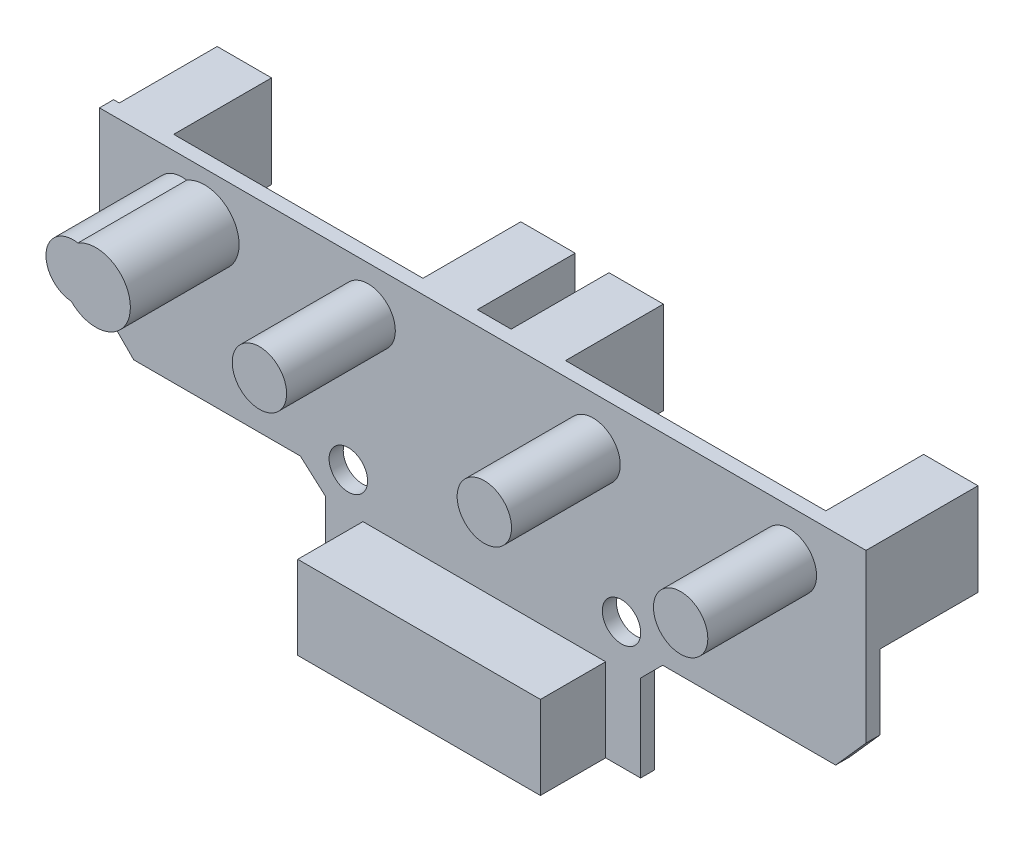
from build123d import *

# Parameters (mm, degrees)
EXTRUDE_1_DEPTH     = 1.3
SKETCH_2_R          = 6.1271e-05
SKETCH_2_R_2        = 1.854699803
CUT_EXTRUDE_1_DEPTH = 1.3
SKETCH_3_W          = 5
SKETCH_3_H          = 8.5
EXTRUDE_2_DEPTH     = 9
SKETCH_4_W          = 22.322793398
SKETCH_4_H          = 7.656611546
EXTRUDE_3_DEPTH     = 6
SKETCH_7_R          = 2.060894962
SKETCH_7_R_2        = 0.009430026
EXTRUDE_6_DEPTH     = 1.3
SKETCH_9_R          = 1.766576119
SKETCH_9_R_2        = 1.77
CUT_EXTRUDE_4_DEPTH = 13.5
SKETCH_11_R         = 2.5
EXTRUDE_7_DEPTH     = 10
SKETCH_5_R          = 3.177873229
EXTRUDE_4_DEPTH     = 10


with BuildPart() as part:
    # 草图1 → 凸台-拉伸1 (new body)
    with BuildSketch(Plane.XY):
        Polygon((-20.731582571, -20.531304637), (-20.731582571, -28.5), (-49.731582571, -28.5), (-49.731582571, -20.531304637), (-52.024986974, -18.5), (-67.347016347, -18.5), (-70.5, -15.347016347), (-70.5, 0), (0, 0), (0, -15.347016347), (-2.792647606, -18.5), (-18.700277933, -18.5), align=None)
    extrude(amount=EXTRUDE_1_DEPTH)

    # 草图2 → 切除-拉伸1 (cut)
    with BuildSketch(Plane(origin=(-0.901876225, 0, 0), x_dir=(-1, 0, 0), z_dir=(0, 0, -1))):
        with Locations((38.822404022, -18.263145779)):
            Circle(SKETCH_2_R)
        with Locations((24.094803283, -18.263145779)):
            Circle(SKETCH_2_R_2)
    extrude(amount=-CUT_EXTRUDE_1_DEPTH, mode=Mode.SUBTRACT)

    # 草图3 → 凸台-拉伸2 (add)
    with BuildSketch(Plane(origin=(0, 0, 0), x_dir=(-1, 0, 0), z_dir=(0, 0, -1))):
        with Locations((2.5, -4.25)):
            Rectangle(SKETCH_3_W, SKETCH_3_H)
        with Locations((31.437833881, -4.25)):
            Rectangle(SKETCH_3_W, SKETCH_3_H)
        with Locations((39.549598659, -4.25)):
            Rectangle(SKETCH_3_W, SKETCH_3_H)
        with Locations((67.475480729, -4.25)):
            Rectangle(SKETCH_3_W, SKETCH_3_H)
    extrude(amount=EXTRUDE_2_DEPTH)

    # 草图4 → 凸台-拉伸3 (add)
    with BuildSketch(Plane.XY.offset(1.3)):
        with Locations((-35.107201512, -24.671694227)):
            Rectangle(SKETCH_4_W, SKETCH_4_H)
    extrude(amount=EXTRUDE_3_DEPTH)

    # 草图7 → 凸台-拉伸6 (add)
    with BuildSketch(Plane(origin=(0, 0, 0), x_dir=(-1, 0, 0), z_dir=(0, 0, -1))):
        with Locations((24.996679508, -18.263145779)):
            Circle(SKETCH_7_R)
        with Locations((22.922712851, -19.688356139)):
            Circle(SKETCH_7_R_2)
    extrude(amount=-EXTRUDE_6_DEPTH)

    # 草图9 → 切除-拉伸4 (cut)
    with BuildSketch(Plane(origin=(0, 0, 0), x_dir=(-1, 0, 0), z_dir=(0, 0, -1))):
        with Locations((22.486064791, -16.932374865)):
            Circle(SKETCH_9_R)
        with Locations((47.612418274, -17.394192754)):
            Circle(SKETCH_9_R_2)
    extrude(amount=-CUT_EXTRUDE_4_DEPTH, mode=Mode.SUBTRACT)

    # 草图11 → 凸台-拉伸7 (add)
    with BuildSketch(Plane.XY.offset(1.3)):
        with Locations((-7.049667213, -4.299078236)):
            Circle(SKETCH_11_R)
        with Locations((-25.10539175, -4.501377507)):
            Circle(SKETCH_11_R)
        with Locations((-45.789989635, -4.160939668)):
            Circle(SKETCH_11_R)
        with Locations((-62.923589595, -4.217113271)):
            Circle(SKETCH_11_R)
    extrude(amount=EXTRUDE_7_DEPTH)

    # 草图5 → 凸台-拉伸4 (add)
    with BuildSketch(Plane.XY.offset(1.3)):
        with Locations((-60.836996038, -4.474043661)):
            Circle(SKETCH_5_R)
    extrude(amount=EXTRUDE_4_DEPTH)


solid = part.part
